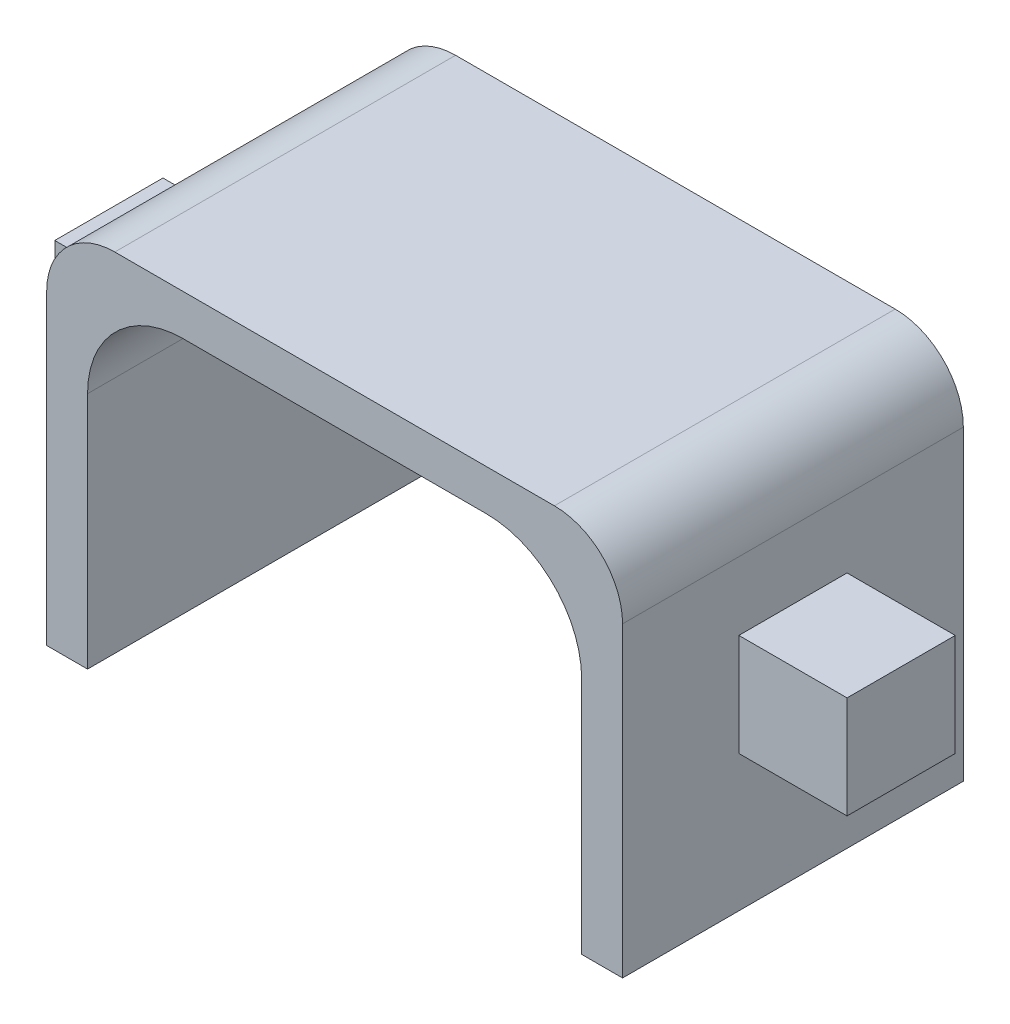
from build123d import *

# Parameters (mm, degrees)
BOSS_EXTRUDE1_DEPTH = 1.5875
BOSS_EXTRUDE2_DEPTH = 5
FILLET1_R           = 2
FILLET2_R           = 2
CUT_EXTRUDE1_DEPTH  = 10


with BuildPart() as part:
    # Sketch1 → Boss-Extrude1 (new body, symmetric)
    with BuildSketch(Plane.XY):
        Polygon((8.45, 11), (8.45, 7), (11.625, 7), (11.625, 4), (8.45, 4), (8.45, 0), (6.45, 0), (6.45, 9), (-6.45, 9), (-6.45, 0), (-8.45, 0), (-8.45, 4), (-11.625, 4), (-11.625, 7), (-8.45, 7), (-8.45, 11), align=None)
    extrude(amount=BOSS_EXTRUDE1_DEPTH, both=True)

    # Sketch2 → Boss-Extrude2 (add, symmetric)
    with BuildSketch(Plane.XY):
        Polygon((-8.45, 7), (-8.45, 4), (-8.45, 0), (-6.45, 0), (-6.45, 9), (6.45, 9), (6.45, 0), (8.45, 0), (8.45, 4), (8.45, 7), (8.45, 11), (-8.45, 11), align=None)
    extrude(amount=BOSS_EXTRUDE2_DEPTH, both=True)

    # Fillet1
    fillet1_edges = [part.edges().sort_by_distance(p)[0] for p in [
        (6.45, 9, 0),
        (-6.45, 9, 0),
    ]]
    fillet(fillet1_edges, radius=FILLET1_R)

    # Fillet2
    fillet2_edges = [part.edges().sort_by_distance(p)[0] for p in [
        (8.45, 11, 0),
        (-8.45, 11, 0),
    ]]
    fillet(fillet2_edges, radius=FILLET2_R)

    # Sketch3 → Cut-Extrude1 (cut)
    with BuildSketch(Plane.XY.offset(5)):
        with BuildLine():
            Line((7.25, 7), (7.25, 0))
            Line((7.25, 0), (6.45, 0))
            Line((6.45, 0), (6.45, 7))
            ThreePointArc((6.45, 7), (5.864213562, 8.414213562), (4.45, 9))
            Line((4.45, 9), (-4.45, 9))
            ThreePointArc((-4.45, 9), (-5.864213562, 8.414213562), (-6.45, 7))
            Line((-6.45, 7), (-6.45, 0))
            Line((-6.45, 0), (-7.25, 0))
            Line((-7.25, 0), (-7.25, 7))
            ThreePointArc((-7.25, 7), (-6.429898987, 8.979898987), (-4.45, 9.8))
            Line((-4.45, 9.8), (4.45, 9.8))
            ThreePointArc((4.45, 9.8), (6.429898987, 8.979898987), (7.25, 7))
        make_face()
    extrude(amount=-CUT_EXTRUDE1_DEPTH, mode=Mode.SUBTRACT)


solid = part.part
